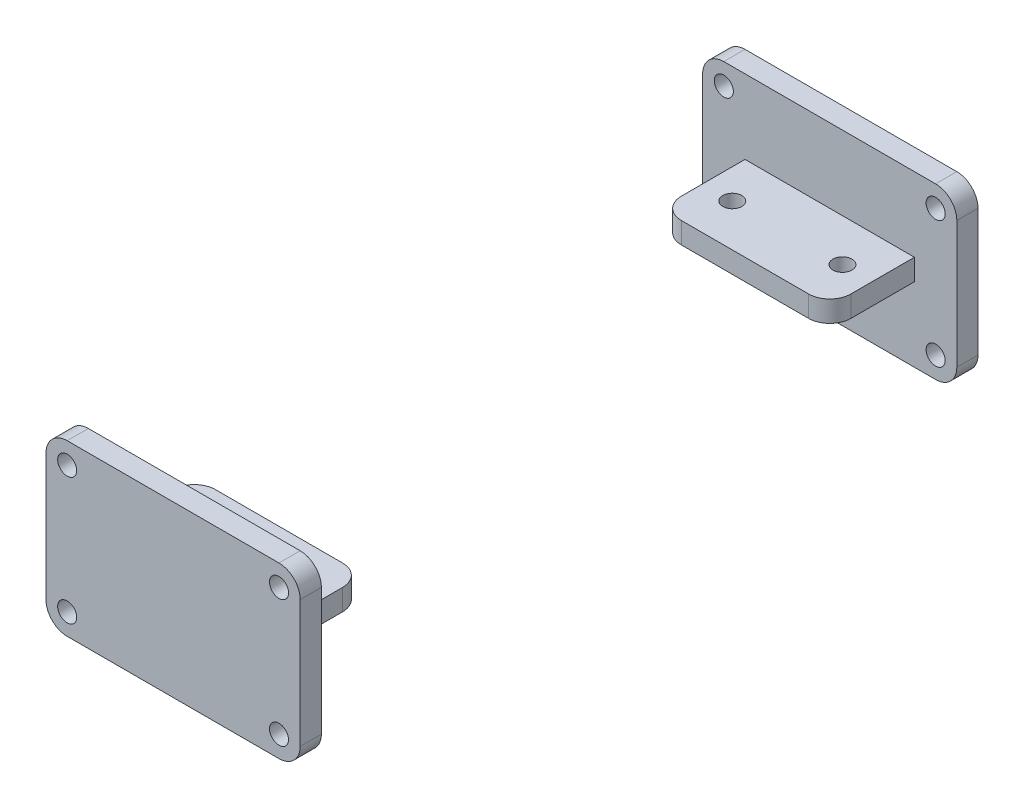
from build123d import *

# Parameters (mm, degrees)
SKETCH1_W               = 120
SKETCH1_H               = 80
BOSS_EXTRUDE1_DEPTH     = 10
FILLET1_R               = 10
FILLET2_R               = 10
FILLET3_R               = 10
FILLET4_R               = 10
SKETCH3_R               = 4.5
CUT_EXTRUDE2_DEPTH      = 10
SKETCH5_W               = 80
SKETCH5_H               = 10
BOSS_EXTRUDE2_DEPTH     = 40
FILLET6_R               = 10
FILLET7_R               = 10
SKETCH6_R               = 4.5
CUT_EXTRUDE3_DEPTH      = 41
CUT_EXTRUDE3_DEPTH_BACK = 41
BODY_MOVE_COPY2_ANGLE   = 180


with BuildPart() as part:
    # Sketch1 → Boss-Extrude1 (new body)
    with BuildSketch(Plane.XY):
        Rectangle(SKETCH1_W, SKETCH1_H)
    extrude(amount=BOSS_EXTRUDE1_DEPTH)

    # Fillet1
    fillet1_edges = [part.edges().sort_by_distance(p)[0] for p in [
        (-60, 40, 5),
    ]]
    fillet(fillet1_edges, radius=FILLET1_R)

    # Fillet2
    fillet2_edges = [part.edges().sort_by_distance(p)[0] for p in [
        (60, -40, 5),
    ]]
    fillet(fillet2_edges, radius=FILLET2_R)

    # Fillet3
    fillet3_edges = [part.edges().sort_by_distance(p)[0] for p in [
        (-60, -40, 5),
    ]]
    fillet(fillet3_edges, radius=FILLET3_R)

    # Fillet4
    fillet4_edges = [part.edges().sort_by_distance(p)[0] for p in [
        (60, 40, 5),
    ]]
    fillet(fillet4_edges, radius=FILLET4_R)

    # Sketch3 → Cut-Extrude2 (cut)
    with BuildSketch(Plane.XY):
        with Locations((50, 30)):
            Circle(SKETCH3_R)
        with Locations((50, -30)):
            Circle(SKETCH3_R)
        with Locations((-50, -30)):
            Circle(SKETCH3_R)
        with Locations((-50, 30)):
            Circle(SKETCH3_R)
    extrude(amount=CUT_EXTRUDE2_DEPTH, mode=Mode.SUBTRACT)

    # Sketch5 → Boss-Extrude2 (add)
    with BuildSketch(Plane.XY):
        Rectangle(SKETCH5_W, SKETCH5_H)
    extrude(amount=-BOSS_EXTRUDE2_DEPTH)

    # Fillet6
    fillet6_edges = [part.edges().sort_by_distance(p)[0] for p in [
        (-40, 0, -40),
    ]]
    fillet(fillet6_edges, radius=FILLET6_R)

    # Fillet7
    fillet7_edges = [part.edges().sort_by_distance(p)[0] for p in [
        (40, 0, -40),
    ]]
    fillet(fillet7_edges, radius=FILLET7_R)

    # Sketch6 → Cut-Extrude3 (cut, two sides)
    with BuildSketch(Plane(origin=(0, 0, 0), x_dir=(1, 0, 0), z_dir=(0, 1, 0))) as cut_extrude3_sk:
        with Locations((-26, 20)):
            Circle(SKETCH6_R)
        with Locations((26, 20)):
            Circle(SKETCH6_R)
    extrude(amount=CUT_EXTRUDE3_DEPTH, mode=Mode.SUBTRACT)
    extrude(cut_extrude3_sk.sketch, amount=-CUT_EXTRUDE3_DEPTH_BACK, mode=Mode.SUBTRACT)


with BuildPart() as body_2:
    # Body-Move/Copy2: copy of part
    add(part.part.rotate(Axis((0, 0, -150), (1, 0, 0)), BODY_MOVE_COPY2_ANGLE))


solid = Compound([part.part, body_2.part])
